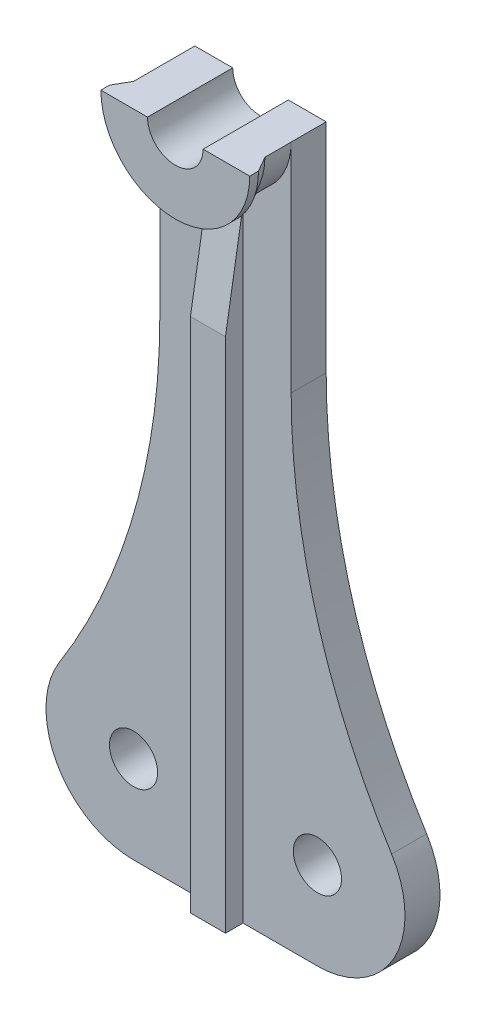
from build123d import *

# Parameters (mm, degrees)
SKETCH1_R           = 2.75
BOSS_EXTRUDE1_DEPTH = 4
REVOLVE1_ANGLE      = 180
BOSS_EXTRUDE2_DEPTH = 2
BOSS_EXTRUDE3_DEPTH = 4


with BuildPart() as part:
    # Sketch1 → Boss-Extrude1 (new body)
    with BuildSketch(Plane.XY):
        with BuildLine():
            Line((-10.5, -60), (-7.5, -60))
            Line((-7.5, -60), (-7.5, 0))
            Line((-7.5, 0), (-3.175, 0))
            ThreePointArc((-3.175, 0), (0, -3.175), (3.175, 0))
            Line((3.175, 0), (7.5, 0))
            Line((7.5, 0), (7.5, -60))
            Line((7.5, -60), (10.5, -60))
            ThreePointArc((10.5, -60), (20.5, -70), (10.5, -80))
            Line((10.5, -80), (-10.5, -80))
            ThreePointArc((-10.5, -80), (-20.5, -70), (-10.5, -60))
        make_face()
        with Locations((-10.5, -70)):
            Circle(SKETCH1_R, mode=Mode.SUBTRACT)
        with Locations((10.5, -70)):
            Circle(SKETCH1_R, mode=Mode.SUBTRACT)
    extrude(amount=BOSS_EXTRUDE1_DEPTH)

    # Sketch2 → Revolve1 (revolve)
    with BuildSketch(Plane(origin=(0, 0, 0), x_dir=(1, 0, 0), z_dir=(0, 1, 0))):
        Polygon((7.5, -4), (3.175, -4), (3.175, -9.732050808), (8.5, -9.732050808), (8.5, -8.732050808), (7.5, -7), align=None)
    revolve(axis=Axis((0, 0, 0), (0, 0, -1)), revolution_arc=REVOLVE1_ANGLE)

    # Sketch3 → Boss-Extrude2 (add, symmetric)
    with BuildSketch(Plane(origin=(0, 0, 0), x_dir=(0, 0, -1), z_dir=(1, 0, 0))):
        Polygon((-4, -9), (-6, -21), (-6, -80), (-4, -80), align=None)
    extrude(amount=BOSS_EXTRUDE2_DEPTH, both=True)

    # Sketch4 → Boss-Extrude3 (add)
    with BuildSketch(Plane.XY.offset(4)):
        with BuildLine():
            Line((-7.5, -60), (-10.5, -60))
            ThreePointArc((-10.5, -60), (-15.339942392, -61.249288164), (-18.970588235, -64.685008471))
            ThreePointArc((-18.970588235, -64.685008471), (-10.424671758, -45.562558961), (-7.5, -24.822572008))
            Line((-7.5, -24.822572008), (-7.5, -60))
        make_face()
        with BuildLine():
            Line((7.5, -60), (7.5, -24.822572008))
            ThreePointArc((7.5, -24.822572008), (10.424671758, -45.562558961), (18.970588235, -64.685008471))
            ThreePointArc((18.970588235, -64.685008471), (15.339942392, -61.249288164), (10.5, -60))
            Line((10.5, -60), (7.5, -60))
        make_face()
    extrude(amount=-BOSS_EXTRUDE3_DEPTH)


solid = part.part
